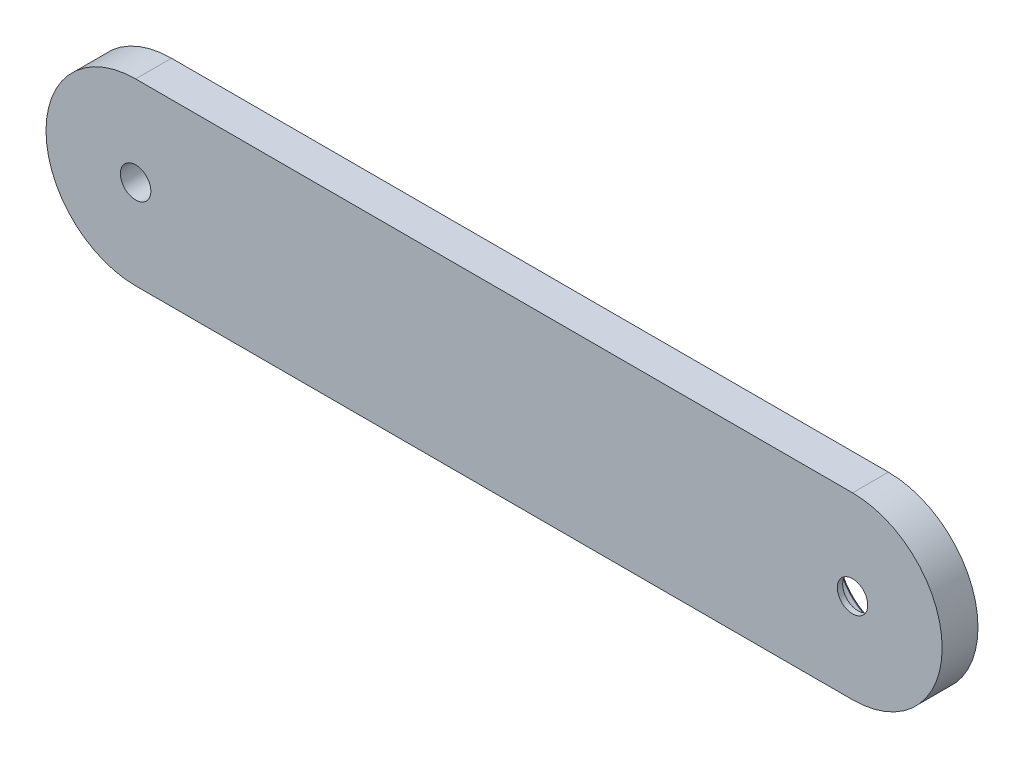
from build123d import *

# Parameters (mm, degrees)
BOSS_EXTRUDE1_DEPTH = 6
SKETCH9_R           = 7.975
CUT_EXTRUDE5_DEPTH  = 5.1
SKETCH10_R          = 2.55
CUT_EXTRUDE6_DEPTH  = 1.9
SKETCH11_R          = 2.55
CUT_EXTRUDE7_DEPTH  = 7
CHAMFER1_SIZE       = 0.5


with BuildPart() as part:
    # Sketch4 → Boss-Extrude1 (new body)
    with BuildSketch(Plane.XY):
        with BuildLine():
            Line((-60, 15), (60, 15))
            ThreePointArc((60, 15), (75, 0), (60, -15))
            Line((60, -15), (-60, -15))
            ThreePointArc((-60, -15), (-75, 0), (-60, 15))
        make_face()
    extrude(amount=BOSS_EXTRUDE1_DEPTH)

    # Sketch9 → Cut-Extrude5 (cut)
    with BuildSketch(Plane(origin=(0, 0, 0), x_dir=(-1, 0, 0), z_dir=(0, 0, -1))):
        with Locations((-60, 0)):
            Circle(SKETCH9_R)
    extrude(amount=-CUT_EXTRUDE5_DEPTH, mode=Mode.SUBTRACT)

    # Sketch10 → Cut-Extrude6 (cut, through all)
    with BuildSketch(Plane(origin=(0, 0, 5.1), x_dir=(-1, 0, 0), z_dir=(0, 0, -1))):
        with Locations((-60, 0)):
            Circle(SKETCH10_R)
    extrude(amount=-CUT_EXTRUDE6_DEPTH, mode=Mode.SUBTRACT)

    # Sketch11 → Cut-Extrude7 (cut, through all)
    with BuildSketch(Plane(origin=(0, 0, 0), x_dir=(-1, 0, 0), z_dir=(0, 0, -1))):
        with Locations((60, 0)):
            Circle(SKETCH11_R)
    extrude(amount=-CUT_EXTRUDE7_DEPTH, mode=Mode.SUBTRACT)

    # Chamfer1
    chamfer1_edges = [part.edges().sort_by_distance(p)[0] for p in [
        (67.975, 0, 0),
    ]]
    chamfer(chamfer1_edges, length=CHAMFER1_SIZE)


solid = part.part
